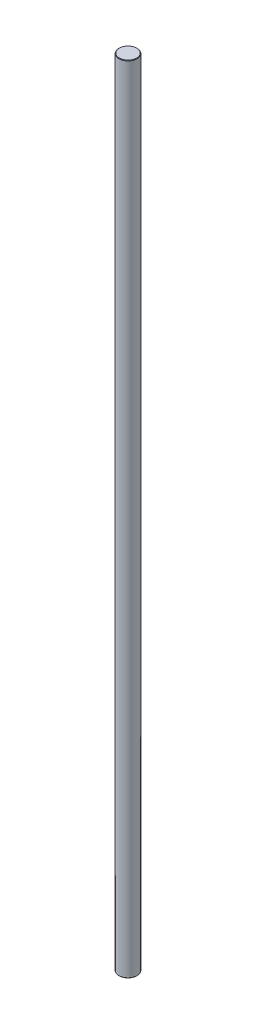
from build123d import *

# Parameters (mm, degrees)
SKETCH1_R           = 4
BOSS_EXTRUDE1_DEPTH = 175
CHAMFER1_SIZE       = 0.2


with BuildPart() as part:
    # Sketch1 → Boss-Extrude1 (new body, symmetric)
    with BuildSketch(Plane(origin=(0, 0, 0), x_dir=(1, 0, 0), z_dir=(0, 1, 0))):
        Circle(SKETCH1_R)
    extrude(amount=BOSS_EXTRUDE1_DEPTH, both=True)

    # Chamfer1
    chamfer1_edges = [part.edges().sort_by_distance(p)[0] for p in [
        (-4, -175, 0),
        (-4, 175, 0),
    ]]
    chamfer(chamfer1_edges, length=CHAMFER1_SIZE)


solid = part.part
